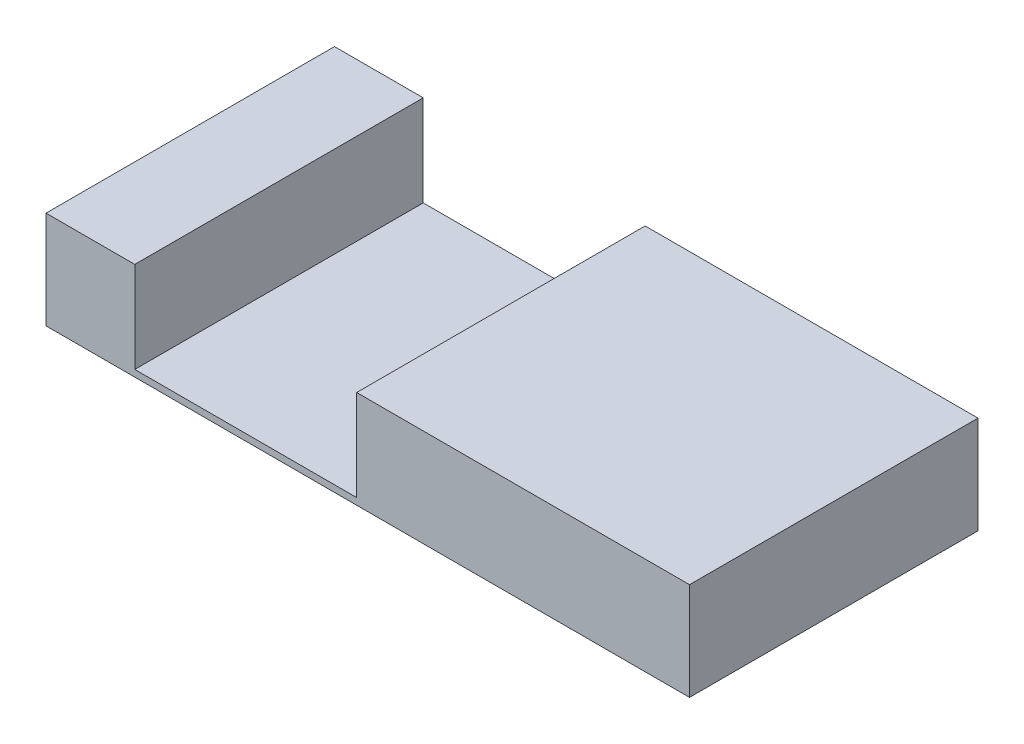
from build123d import *

# Parameters (mm, degrees)
SKETCH1_W           = 145
SKETCH1_H           = 65
BOSS_EXTRUDE1_DEPTH = 11
SKETCH2_W           = 50
SKETCH2_H           = 65
CUT_EXTRUDE1_DEPTH  = 20.5


with BuildPart() as part:
    # Sketch1 → Boss-Extrude1 (new body, symmetric)
    with BuildSketch(Plane(origin=(0, 0, 0), x_dir=(1, 0, 0), z_dir=(0, 1, 0))):
        Rectangle(SKETCH1_W, SKETCH1_H)
    extrude(amount=BOSS_EXTRUDE1_DEPTH, both=True)

    # Sketch2 → Cut-Extrude1 (cut)
    with BuildSketch(Plane(origin=(0, 11, 0), x_dir=(1, 0, 0), z_dir=(0, 1, 0))):
        with Locations((-27.5, 0)):
            Rectangle(SKETCH2_W, SKETCH2_H)
    extrude(amount=-CUT_EXTRUDE1_DEPTH, mode=Mode.SUBTRACT)


solid = part.part
